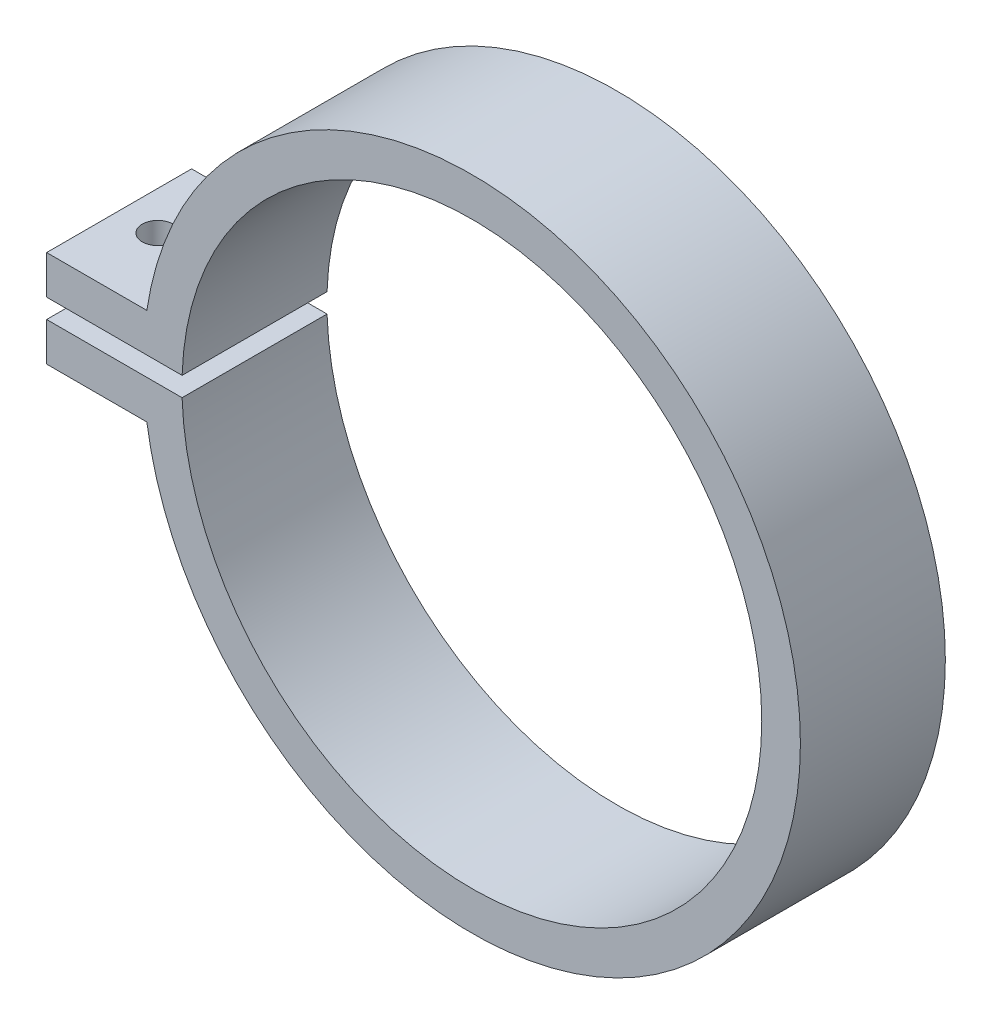
from build123d import *

# Parameters (mm, degrees)
SKETCH1_R               = 34
BOSS_EXTRUDE1_DEPTH     = 7.5
SKETCH4_W               = 44
SKETCH4_H               = 10
BOSS_EXTRUDE2_DEPTH     = 7.5
SKETCH5_R               = 30
SKETCH5_W               = 44
SKETCH5_H               = 2
CUT_EXTRUDE1_DEPTH      = 26.5
SKETCH6_R               = 1.6
CUT_EXTRUDE2_DEPTH      = 30
CUT_EXTRUDE2_DEPTH_BACK = 10


with BuildPart() as part:
    # Sketch1 → Boss-Extrude1 (new body, symmetric)
    with BuildSketch(Plane.XY):
        Circle(SKETCH1_R)
    extrude(amount=BOSS_EXTRUDE1_DEPTH, both=True)

    # Sketch4 → Boss-Extrude2 (add, symmetric)
    with BuildSketch(Plane.XY):
        with Locations((-22, 0)):
            Rectangle(SKETCH4_W, SKETCH4_H)
    extrude(amount=BOSS_EXTRUDE2_DEPTH, both=True)

    # Sketch5 → Cut-Extrude1 (cut)
    with BuildSketch(Plane.XY.offset(7.5)):
        Circle(SKETCH5_R)
        with Locations((-22, 0)):
            Rectangle(SKETCH5_W, SKETCH5_H)
    extrude(amount=-CUT_EXTRUDE1_DEPTH, mode=Mode.SUBTRACT)

    # Sketch6 → Cut-Extrude2 (cut, two sides)
    with BuildSketch(Plane(origin=(0, 5, 0), x_dir=(1, 0, 0), z_dir=(0, 1, 0))) as cut_extrude2_sk:
        with Locations((-40, 0)):
            Circle(SKETCH6_R)
    extrude(amount=CUT_EXTRUDE2_DEPTH, mode=Mode.SUBTRACT)
    extrude(cut_extrude2_sk.sketch, amount=-CUT_EXTRUDE2_DEPTH_BACK, mode=Mode.SUBTRACT)


solid = part.part
